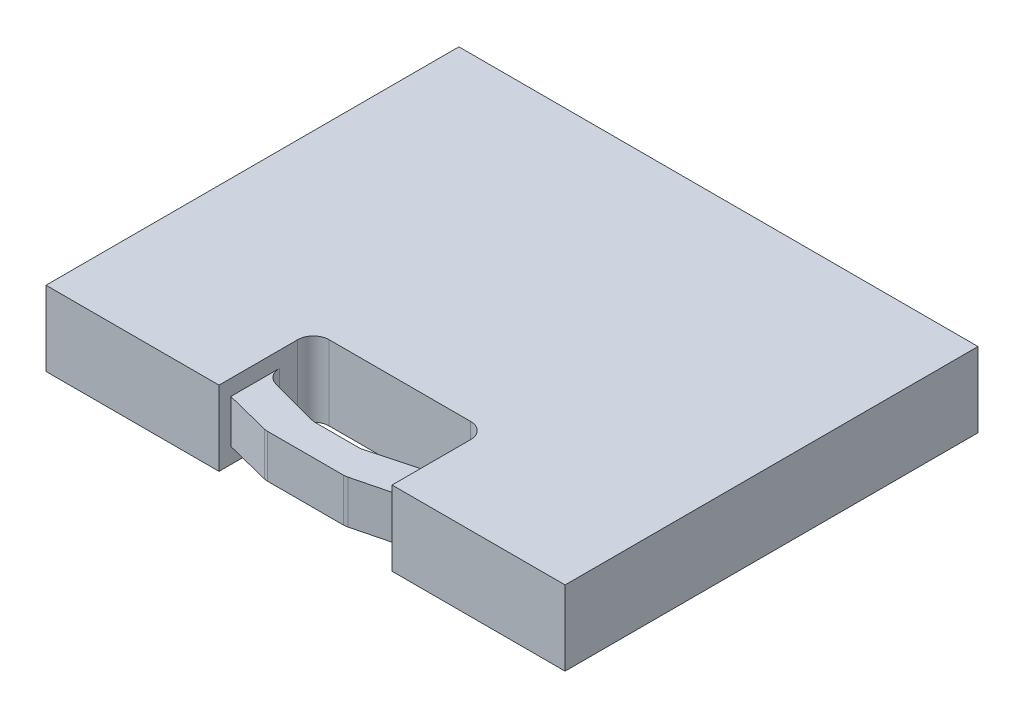
from build123d import *

# Parameters (mm, degrees)
SKETCH1_W           = 419.1
SKETCH1_H           = 333.375
BOSS_EXTRUDE1_DEPTH = 60.325
SKETCH2_W           = 139.7
SKETCH2_H           = 50.8
CUT_EXTRUDE1_DEPTH  = 61.325
CHAMFER1_SIZE       = 50.8
CHAMFER1_SIZE2      = 13.611818976
FILLET1_R           = 12.7
SKETCH3_W           = 139.7
SKETCH3_H           = 56.403006085
CUT_EXTRUDE2_DEPTH  = 12.7
SKETCH4_W           = 139.7
SKETCH4_H           = 56.128435861
CUT_EXTRUDE3_DEPTH  = 12.7


with BuildPart() as part:
    # Sketch1 → Boss-Extrude1 (new body)
    with BuildSketch(Plane(origin=(0, 0, 0), x_dir=(1, 0, 0), z_dir=(0, 1, 0))):
        Rectangle(SKETCH1_W, SKETCH1_H)
    extrude(amount=BOSS_EXTRUDE1_DEPTH)

    # Sketch2 → Cut-Extrude1 (cut, through all)
    with BuildSketch(Plane(origin=(0, 60.325, 0), x_dir=(1, 0, 0), z_dir=(0, 1, 0))):
        with Locations((0, -115.8875)):
            Rectangle(SKETCH2_W, SKETCH2_H)
        Polygon((-69.85, -166.6875), (-69.85, -157.1625), (-32.169017961, -166.6875), align=None)
        Polygon((32.169017961, -166.6875), (69.85, -166.6875), (69.85, -157.1625), align=None)
    extrude(amount=-CUT_EXTRUDE1_DEPTH, mode=Mode.SUBTRACT)

    # Chamfer1
    chamfer1_edges = [part.edges().sort_by_distance(p)[0] for p in [
        (69.85, 30.1625, 141.2875),
        (-69.85, 30.1625, 141.2875),
    ]]
    chamfer1_side = [part.faces().sort_by_distance(p)[0] for p in [
        (0, 30.1625, 141.2875),
    ]]
    chamfer(chamfer1_edges, length=CHAMFER1_SIZE, length2=CHAMFER1_SIZE2, reference=chamfer1_side[0])

    # Fillet1
    fillet1_edges = [part.edges().sort_by_distance(p)[0] for p in [
        (69.85, 30.1625, 90.4875),
        (-69.85, 30.1625, 90.4875),
        (-32.169017961, 30.1625, 166.6875),
        (32.169017961, 30.1625, 166.6875),
        (69.85, 30.1625, 127.675681024),
        (-19.05, 30.1625, 141.2875),
        (19.05, 30.1625, 141.2875),
        (-69.85, 30.1625, 127.675681024),
    ]]
    fillet(fillet1_edges, radius=FILLET1_R)

    # Sketch3 → Cut-Extrude2 (cut)
    with BuildSketch(Plane(origin=(0, 60.325, 0), x_dir=(1, 0, 0), z_dir=(0, 1, 0))):
        with Locations((0, -138.485996957)):
            Rectangle(SKETCH3_W, SKETCH3_H)
    extrude(amount=-CUT_EXTRUDE2_DEPTH, mode=Mode.SUBTRACT)

    # Sketch4 → Cut-Extrude3 (cut)
    with BuildSketch(Plane.XZ):
        with Locations((0, 138.623282069)):
            Rectangle(SKETCH4_W, SKETCH4_H)
    extrude(amount=-CUT_EXTRUDE3_DEPTH, mode=Mode.SUBTRACT)


solid = part.part
